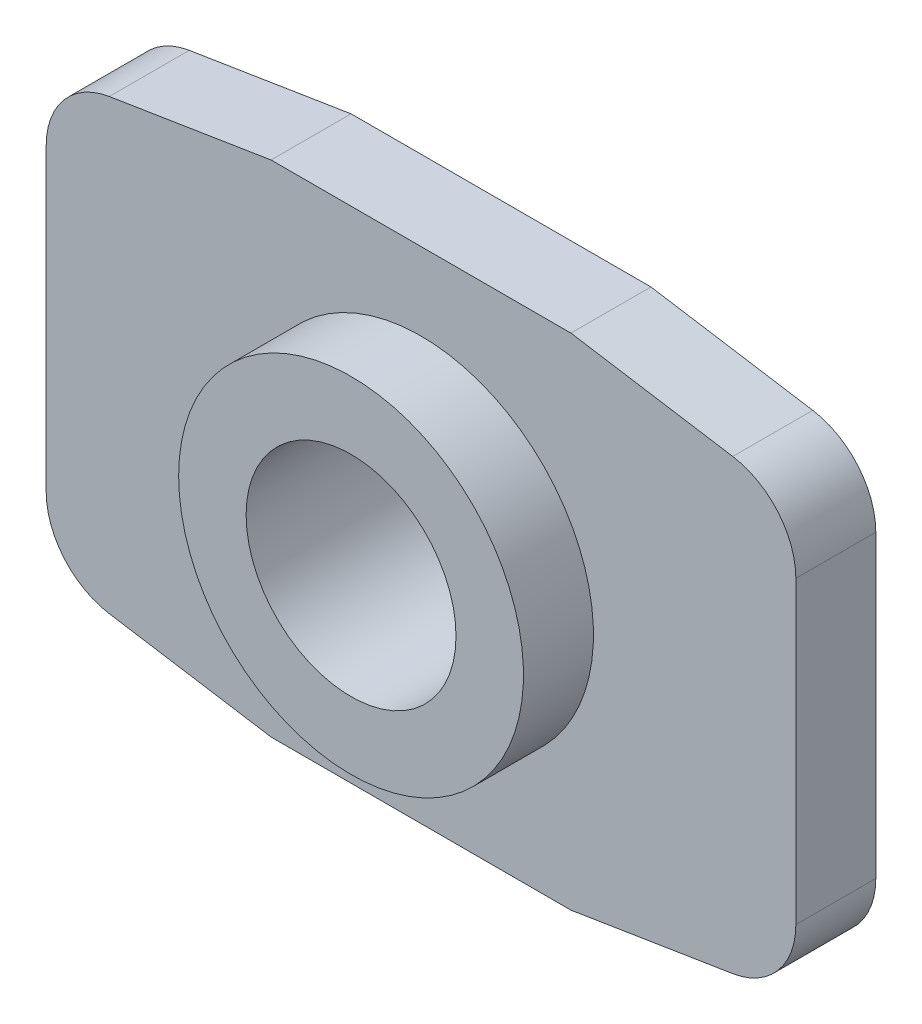
from build123d import *

# Parameters (mm, degrees)
BOSS_EXTRUDE1_DEPTH = 1.6
DRAFT1_ANGLE        = 9.10617604
SKETCH2_W           = 3.45
SKETCH2_H           = 1.4
HOLE1_D             = 4.2
HOLE1_DEPTH         = 3
FILLET1_R           = 1.5


with BuildPart() as part:
    # Sketch1 → Boss-Extrude1 (new body)
    with BuildSketch(Plane.XY.offset(1.6)):
        Polygon((3, -5), (6.092206474, -4.504366896), (7.5, 4.278719262), (3, 5), (-3, 5), (-7.5, 4.278719262), (-7.5, -4.278719262), (-3, -5), align=None)
    extrude(amount=-BOSS_EXTRUDE1_DEPTH)

    # Draft1
    draft1_faces = [part.faces().sort_by_distance(p)[0] for p in [
        (6.796103237, -0.112823817, 0.8),
    ]]
    draft(draft1_faces, Plane(origin=(7.5, 4.278719262, 0), x_dir=(0.987396753, -0.158264502, 0), z_dir=(0.158264502, 0.987396753, 0)), DRAFT1_ANGLE)

    # Sketch2 → Revolve1 (revolve)
    with BuildSketch(Plane.XZ):
        with Locations((1.725, 2.3)):
            Rectangle(SKETCH2_W, SKETCH2_H)
    revolve(axis=Axis((0, 0, 3), (0, 0, -1)))

    # Hole1
    with Locations(Plane.XY.offset(3)):
        with Locations((0, 0)):
            Hole(HOLE1_D / 2, depth=HOLE1_DEPTH)

    # Fillet1
    fillet1_edges = [part.edges().sort_by_distance(p)[0] for p in [
        (-7.5, -4.278719262, 0.8),
        (-7.5, 4.278719262, 0.8),
        (7.5, 4.278719262, 0.8),
        (7.5, -4.278719262, 0.8),
    ]]
    fillet(fillet1_edges, radius=FILLET1_R)


solid = part.part
